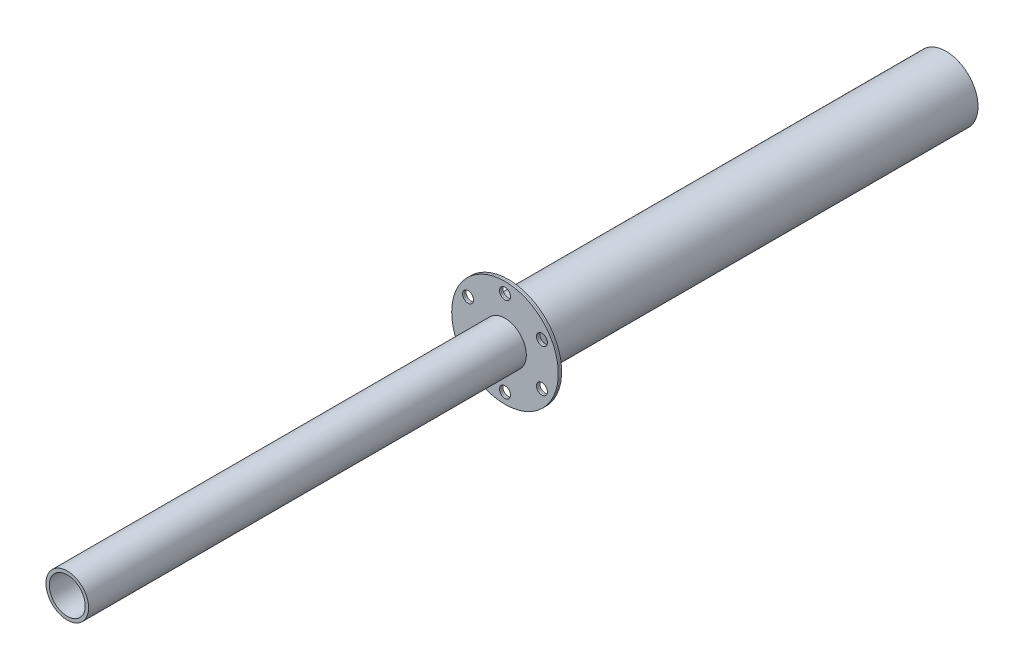
from build123d import *

# Parameters (mm, degrees)
SKETCH1_R                     = 12.7
SKETCH1_R_2                   = 10.7
BOSS_EXTRUDEINNERTUBE_DEPTH   = 261.7
SKETCH2_R                     = 31.75
SKETCH2_R_2                   = 12.7
SKETCH2_R_3                   = 3.2639
BOSS_EXTRUDEFRONTFLANGE_DEPTH = 1
SKETCH3_R                     = 19.05
SKETCH3_R_2                   = 17.85
BOSS_EXTRUDEOUTERTUBE_DEPTH   = 261.7
SKETCH4_R                     = 31.75
SKETCH4_R_2                   = 3.2639
SKETCH4_R_3                   = 19.05
BOSS_EXTRUDEREARFLANGE_DEPTH  = 1


with BuildPart() as part:
    # Sketch1 → Boss-ExtrudeInnerTube (new body)
    with BuildSketch(Plane.XY):
        Circle(SKETCH1_R)
        Circle(SKETCH1_R_2, mode=Mode.SUBTRACT)
    extrude(amount=-BOSS_EXTRUDEINNERTUBE_DEPTH)


with BuildPart() as body_2:
    # Sketch2 → Boss-ExtrudeFrontFlange (new body)
    with BuildSketch(Plane(origin=(0, 0, -261.7), x_dir=(-1, 0, 0), z_dir=(0, 0, -1))):
        Circle(SKETCH2_R)
        Circle(SKETCH2_R_2, mode=Mode.SUBTRACT)
        with Locations((0, 25.4)):
            Circle(SKETCH2_R_3, mode=Mode.SUBTRACT)
        with Locations((21.997045256, 12.7)):
            Circle(SKETCH2_R_3, mode=Mode.SUBTRACT)
        with Locations((21.997045256, -12.7)):
            Circle(SKETCH2_R_3, mode=Mode.SUBTRACT)
        with Locations((0, -25.4)):
            Circle(SKETCH2_R_3, mode=Mode.SUBTRACT)
        with Locations((-21.997045256, -12.7)):
            Circle(SKETCH2_R_3, mode=Mode.SUBTRACT)
        with Locations((-21.997045256, 12.7)):
            Circle(SKETCH2_R_3, mode=Mode.SUBTRACT)
    extrude(amount=-BOSS_EXTRUDEFRONTFLANGE_DEPTH)


with BuildPart() as body_3:
    # Sketch3 → Boss-ExtrudeOuterTube (new body)
    with BuildSketch(Plane(origin=(0, 0, -261.7), x_dir=(-1, 0, 0), z_dir=(0, 0, -1))):
        Circle(SKETCH3_R)
        Circle(SKETCH3_R_2, mode=Mode.SUBTRACT)
    extrude(amount=BOSS_EXTRUDEOUTERTUBE_DEPTH)


with BuildPart() as body_4:
    # Sketch4 → Boss-ExtrudeRearFlange (new body)
    with BuildSketch(Plane(origin=(0, 0, -261.7), x_dir=(-1, 0, 0), z_dir=(0, 0, -1))):
        Circle(SKETCH4_R)
        with Locations((-21.997045256, 12.7)):
            Circle(SKETCH4_R_2, mode=Mode.SUBTRACT)
        with Locations((0, 25.4)):
            Circle(SKETCH4_R_2, mode=Mode.SUBTRACT)
        with Locations((-21.997045256, -12.7)):
            Circle(SKETCH4_R_2, mode=Mode.SUBTRACT)
        with Locations((21.997045256, 12.7)):
            Circle(SKETCH4_R_2, mode=Mode.SUBTRACT)
        with Locations((21.997045256, -12.7)):
            Circle(SKETCH4_R_2, mode=Mode.SUBTRACT)
        with Locations((0, -25.4)):
            Circle(SKETCH4_R_2, mode=Mode.SUBTRACT)
        Circle(SKETCH4_R_3, mode=Mode.SUBTRACT)
    extrude(amount=BOSS_EXTRUDEREARFLANGE_DEPTH)


solid = Compound([part.part, body_2.part, body_3.part, body_4.part])
